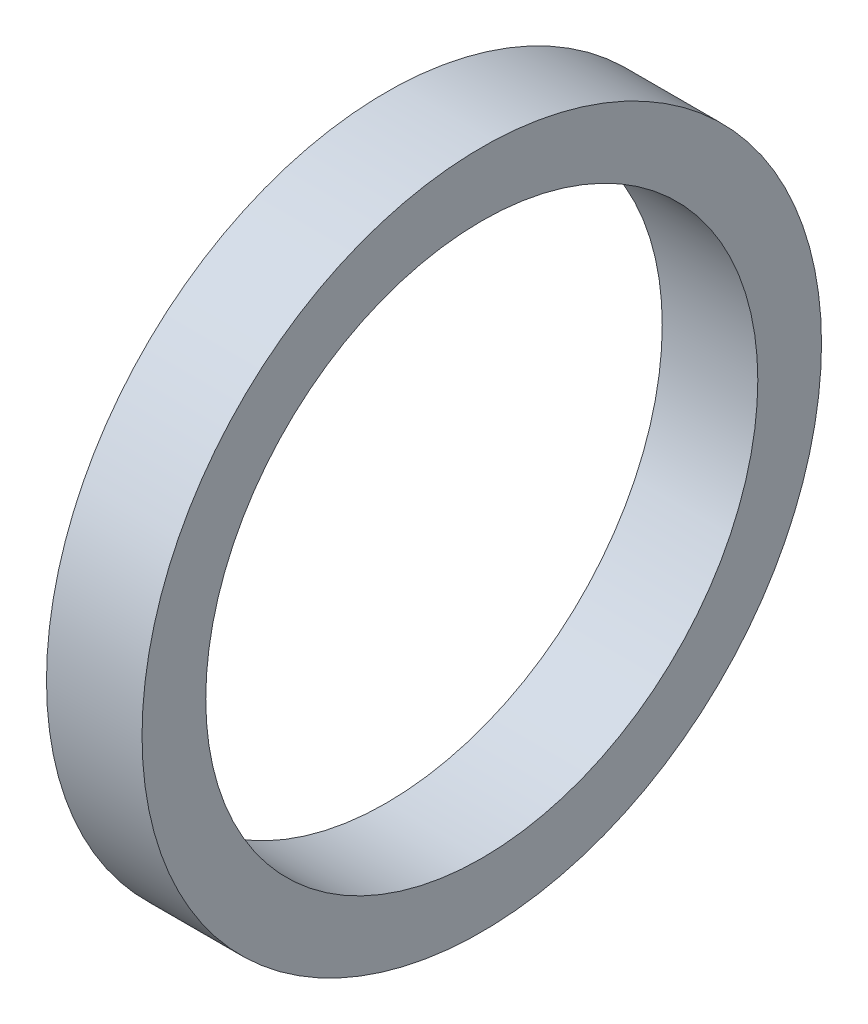
from build123d import *

# Parameters (mm, degrees)
SKETCH_1_W = 4.5
SKETCH_1_H = 3


with BuildPart() as part:
    # 草图1 → 旋转1 (revolve)
    with BuildSketch(Plane(origin=(352.92895665, -174.926688854, -1654.000174855), x_dir=(-1, 0, 0), z_dir=(0, 0.609344086, -0.792905912))):
        with Locations((11.069850069, -607.851034956)):
            Rectangle(SKETCH_1_W, SKETCH_1_H)
    revolve(axis=Axis((338.546606581, -668.392503518, -2033.226097582), (1, 0, 0)))


solid = part.part
